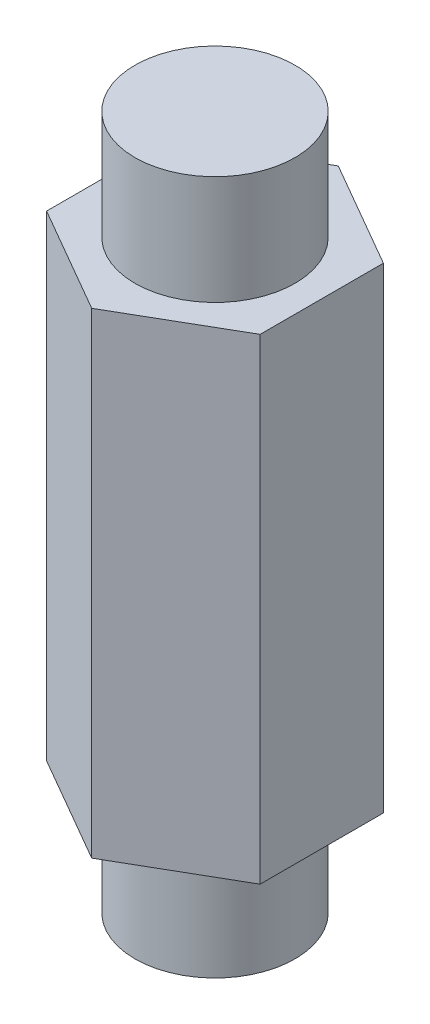
from build123d import *

# Parameters (mm, degrees)
BOSS_EXTRUDE1_DEPTH = 14.1605
SKETCH2_R           = 4.7625
BOSS_EXTRUDE2_DEPTH = 20.6375


with BuildPart() as part:
    # Sketch1 → Boss-Extrude1 (new body, symmetric)
    with BuildSketch(Plane(origin=(0, 0, 0), x_dir=(1, 0, 0), z_dir=(0, 1, 0))):
        Polygon((6.35, -3.666174209), (6.35, 3.666174209), (0, 7.332348419), (-6.35, 3.666174209), (-6.35, -3.666174209), (0, -7.332348419), align=None)
    extrude(amount=BOSS_EXTRUDE1_DEPTH, both=True)

    # Sketch2 → Boss-Extrude2 (add, symmetric)
    with BuildSketch(Plane(origin=(0, 0, 0), x_dir=(1, 0, 0), z_dir=(0, 1, 0))):
        Circle(SKETCH2_R)
    extrude(amount=BOSS_EXTRUDE2_DEPTH, both=True)


solid = part.part
